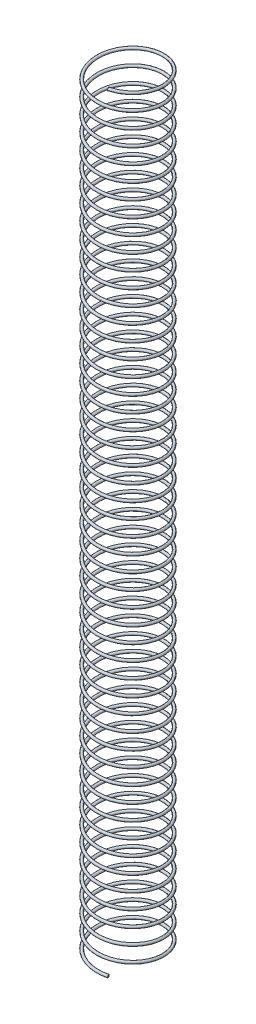
from build123d import *

# Parameters (mm, degrees)
SWEEP1_PITCH       = 5.715
SWEEP1_HEIGHT      = 285.75
SWEEP1_RADIUS      = 12.192
SWEEP1_START_ANGLE = 20
SKETCH5_R          = 0.508


with BuildPart() as part:
    # Sweep1: sweep along a helix
    with BuildLine() as sweep1_path:
        add(Helix(SWEEP1_PITCH, SWEEP1_HEIGHT, SWEEP1_RADIUS, center=(0, 0, 0), direction=(0, 1, 0), lefthand=True, mode=Mode.PRIVATE).rotate(Axis((0, 0, 0), (0, 1, 0)), SWEEP1_START_ANGLE))
    # Sketch5 → Sweep1 (sweep)
    with BuildSketch(Plane(origin=(4.169909587, 285.75, 11.456732433), x_dir=(0.340002457, -0.026993404, 0.940037066), z_dir=(-0.937088445, 0.074397129, 0.341072301))):
        with Locations((0.002020386, -0.001988623)):
            Circle(SKETCH5_R)
    sweep(path=sweep1_path.line, is_frenet=True)


solid = part.part
